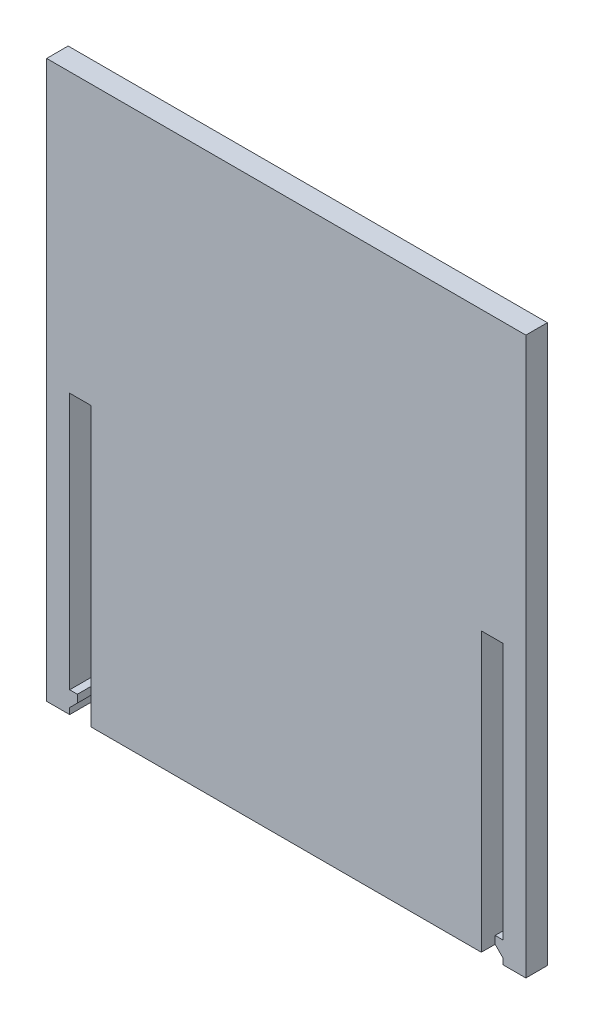
from build123d import *

# Parameters (mm, degrees)
SKETCH1_W           = 62.4
SKETCH1_H           = 72.5
SKETCH1_W_2         = 2.8
SKETCH1_H_2         = 33.45
BOSS_EXTRUDE1_DEPTH = 2.8
CUT_EXTRUDE1_DEPTH  = 3.8


with BuildPart() as part:
    # Sketch1 → Boss-Extrude1 (new body)
    with BuildSketch(Plane.XY):
        with Locations((25.4, 22.394209189)):
            Rectangle(SKETCH1_W, SKETCH1_H)
        with Locations((-1.4, 5.669209189)):
            Rectangle(SKETCH1_W_2, SKETCH1_H_2, mode=Mode.SUBTRACT)
        with Locations((52.2, 5.669209189)):
            Rectangle(SKETCH1_W_2, SKETCH1_H_2, mode=Mode.SUBTRACT)
    extrude(amount=BOSS_EXTRUDE1_DEPTH)

    # Sketch2 → Cut-Extrude1 (cut, through all)
    with BuildSketch(Plane.XY.offset(2.8)):
        Polygon((0, -11.055790811), (-1.8, -11.055790811), (-1.8, -12.055790811), (-2.8, -13.055790811), (-2.8, -13.855790811), (0, -13.855790811), align=None)
    cut_extrude1 = extrude(amount=-CUT_EXTRUDE1_DEPTH, mode=Mode.SUBTRACT)

    # Mirror1: Cut-Extrude1 across plane
    add(cut_extrude1.mirror(Plane.ZY.offset(-25.4)), mode=Mode.SUBTRACT)


solid = part.part
